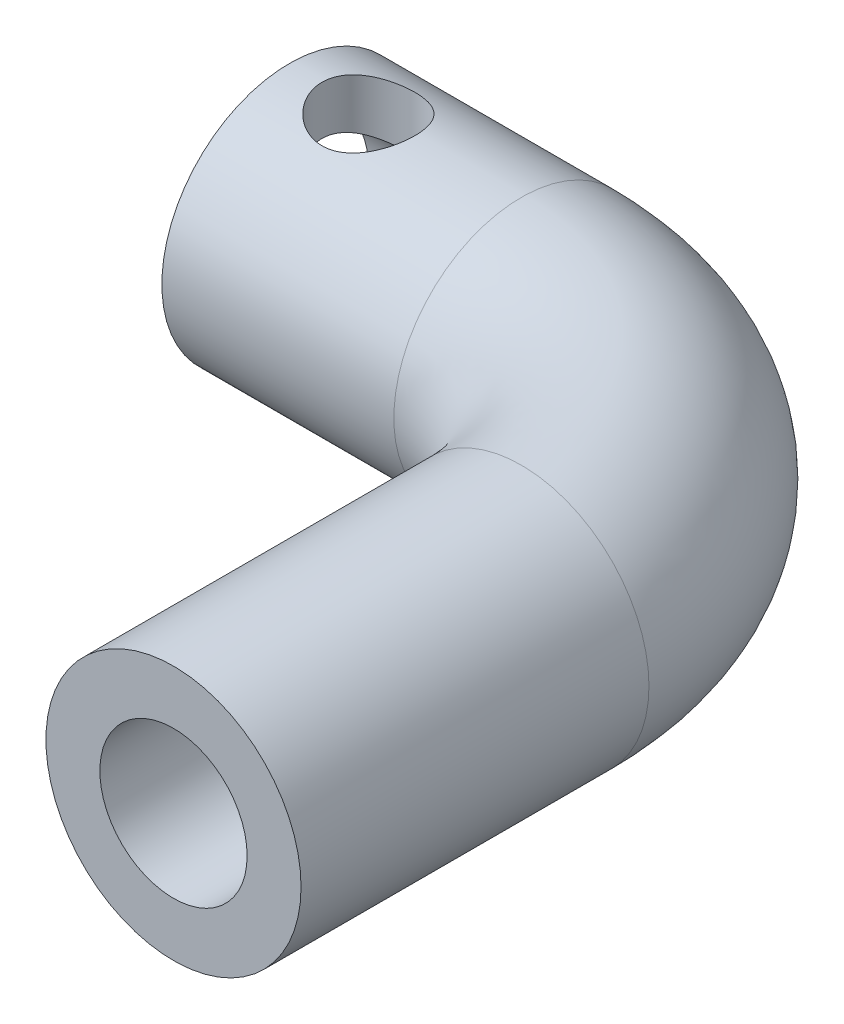
from build123d import *

# Parameters (mm, degrees)
SKETCH4_R         = 5.5
SKETCH6_R         = 3.175
HOLE_SHAFT_DEPTH  = 10
SKETCH7_R         = 3.4
HOLE_POT_DEPTH    = 10
SKETCH8_R         = 2
HOLE_INSERT_DEPTH = 32.008063485
SLOT_BOSS_DEPTH   = 1


with BuildPart() as part:
    # Sweep2: sweep along a path in PROFILE
    with BuildLine(Plane(origin=(0, 0, 0), x_dir=(1, 0, 0), z_dir=(0, 1, 0))) as sweep2_path:
        Line((2.5, -25), (2.5, -10))
        ThreePointArc((2.5, -10), (-0.428932188, -2.928932188), (-7.5, 0))
        Line((-7.5, 0), (-17.5, 0))
    # Sketch4 → Sweep2 (sweep)
    with BuildSketch(Plane.XY.offset(25)):
        with Locations((2.5, 0)):
            Circle(SKETCH4_R)
    sweep(path=sweep2_path.line)

    # Sketch6 → HOLE_SHAFT (cut)
    with BuildSketch(Plane.XY.offset(25)):
        with Locations((2.5, 0)):
            Circle(SKETCH6_R)
    extrude(amount=-HOLE_SHAFT_DEPTH, mode=Mode.SUBTRACT)

    # Sketch7 → HOLE_POT (cut)
    with BuildSketch(Plane.ZY.offset(17.5)):
        Circle(SKETCH7_R)
    extrude(amount=-HOLE_POT_DEPTH, mode=Mode.SUBTRACT)

    # Sketch8 → HOLE_INSERT (cut, through all)
    with BuildSketch(Plane(origin=(0, 0, 0), x_dir=(1, 0, 0), z_dir=(0, 1, 0))):
        with Locations((-14.096251262, 0)):
            Circle(SKETCH8_R)
    extrude(amount=HOLE_INSERT_DEPTH, mode=Mode.SUBTRACT)

    # Sketch11 → SLOT_BOSS (add)
    with BuildSketch(Plane.ZY.offset(7.5)):
        Polygon((1.645649924, -2.879269115), (-2.456130729, 2.466275506), (-1.662777389, 3.075036935), (2.439003264, -2.270507686), align=None)
    extrude(amount=SLOT_BOSS_DEPTH)


solid = part.part
